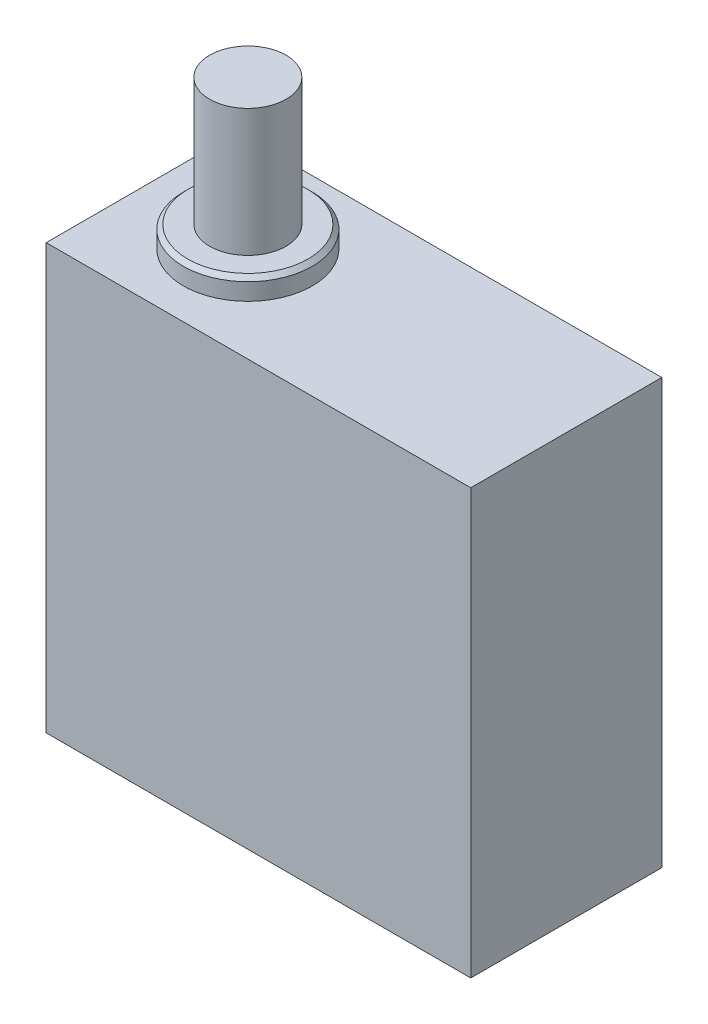
from build123d import *

# Parameters (mm, degrees)
ESQUISSE1_W        = 20
ESQUISSE1_H        = 20
BOSS_EXTRU_1_DEPTH = 9
BOSS_EXTRU_2_DEPTH = 1
CHANFREIN1_SIZE    = 0.2
ESQUISSE4_R        = 1.8000000000000007
BOSS_EXTRU_3_DEPTH = 6


with BuildPart() as part:
    # Esquisse1 → Boss.-Extru.1 (new body)
    with BuildSketch(Plane.XY):
        with Locations((10, 10)):
            Rectangle(ESQUISSE1_W, ESQUISSE1_H)
    extrude(amount=BOSS_EXTRU_1_DEPTH)

    # Esquisse2 → Boss.-Extru.2 (add)
    with BuildSketch(Plane(origin=(0, 20, 0), x_dir=(1, 0, 0), z_dir=(0, 1, 0))):
        with BuildLine():
            ThreePointArc((7.256081239041076, -2.4695268848630905), (5.0000000000000115, -1.4647531190285523), (2.7439187609589397, -2.469526884863073))
            Line((2.743918760958954, -2.4695268848630585), (5.000000000000001, -4.500000000000001))
            Line((5.000000000000001, -4.499999999999999), (7.256081239041048, -2.4695268848630567))
        make_face()
        with BuildLine():
            Line((5.000000000000001, -4.500000000000001), (2.743918760958954, -2.4695268848630585))
            ThreePointArc((2.7439187609589397, -2.469526884863073), (1.9647531190285523, -4.5), (2.743918760958939, -6.530473115136926))
            Line((2.743918760958954, -6.5304731151369415), (5.000000000000001, -4.499999999999999))
        make_face()
        with BuildLine():
            Line((7.256081239041048, -2.4695268848630567), (5.000000000000001, -4.499999999999999))
            Line((5.000000000000001, -4.500000000000001), (7.256081239041048, -6.530473115136943))
            ThreePointArc((7.256081239041075, -6.53047311513691), (7.833768442592348, -5.587418981908373), (8.035246880971448, -4.500000000000001))
            ThreePointArc((8.035246880971448, -4.5), (7.833768442592348, -3.412581018091629), (7.256081239041075, -2.46952688486309))
        make_face()
        with BuildLine():
            Line((7.256081239041048, -6.530473115136943), (5.000000000000001, -4.500000000000001))
            Line((5.000000000000001, -4.499999999999999), (2.743918760958954, -6.5304731151369415))
            ThreePointArc((2.743918760958939, -6.530473115136926), (5.000000000000011, -7.535246880971448), (7.256081239041075, -6.53047311513691))
        make_face()
    extrude(amount=BOSS_EXTRU_2_DEPTH)

    # Chanfrein1
    chanfrein1_edges = [part.edges().sort_by_distance(p)[0] for p in [
        (7.256081239041057, 21, 2.469526884863065),
    ]]
    chamfer(chanfrein1_edges, length=CHANFREIN1_SIZE)

    # Esquisse4 → Boss.-Extru.3 (add)
    with BuildSketch(Plane(origin=(0, 21, 0), x_dir=(1, 0, 0), z_dir=(0, 1, 0))):
        with Locations(Location((5, -4.5, 0), (0, 0, 270))):
            Circle(ESQUISSE4_R)
    extrude(amount=BOSS_EXTRU_3_DEPTH)


solid = part.part
